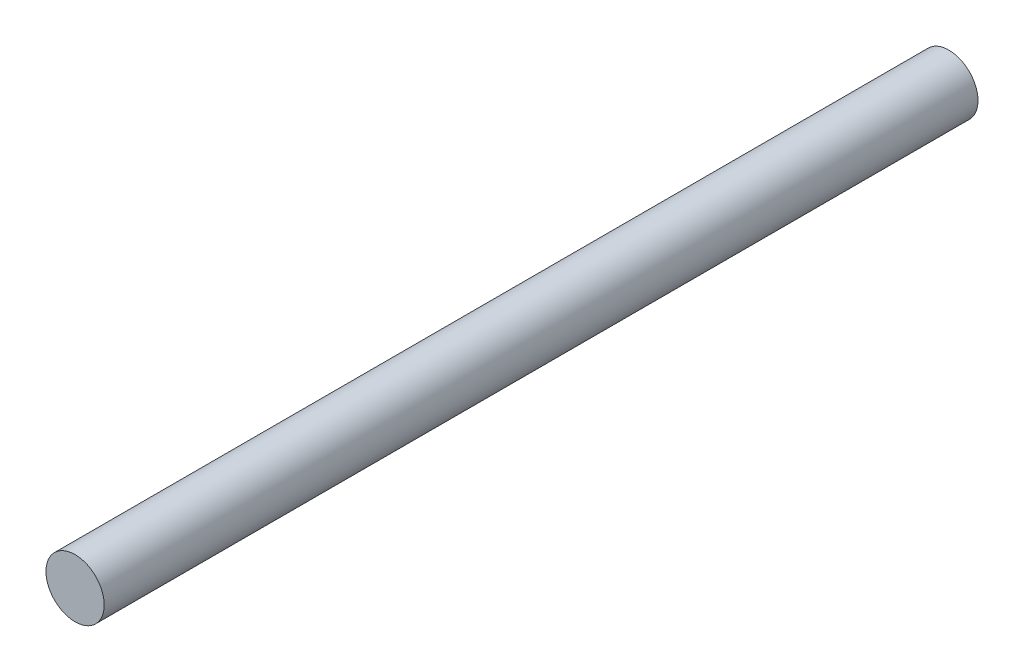
from build123d import *

# Parameters (mm, degrees)
SKETCH1_R           = 1.5
BOSS_EXTRUDE1_DEPTH = 45


with BuildPart() as part:
    # Sketch1 → Boss-Extrude1 (new body)
    with BuildSketch(Plane.XY):
        Circle(SKETCH1_R)
    extrude(amount=BOSS_EXTRUDE1_DEPTH)


solid = part.part
